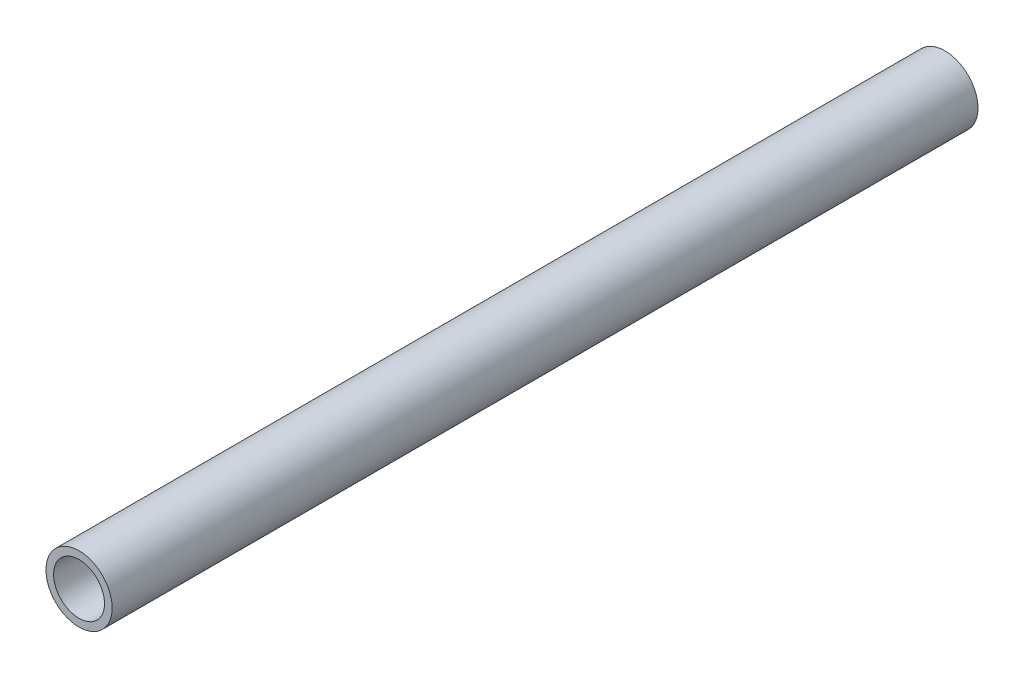
from build123d import *

# Parameters (mm, degrees)
SKETCH1_R           = 6.5
SKETCH1_R_2         = 5
EXTRUDE_THIN1_DEPTH = 170


with BuildPart() as part:
    # Sketch1 → Extrude-Thin1 (new body)
    with BuildSketch(Plane.XY):
        Circle(SKETCH1_R)
        Circle(SKETCH1_R_2, mode=Mode.SUBTRACT)
    extrude(amount=EXTRUDE_THIN1_DEPTH)


solid = part.part
